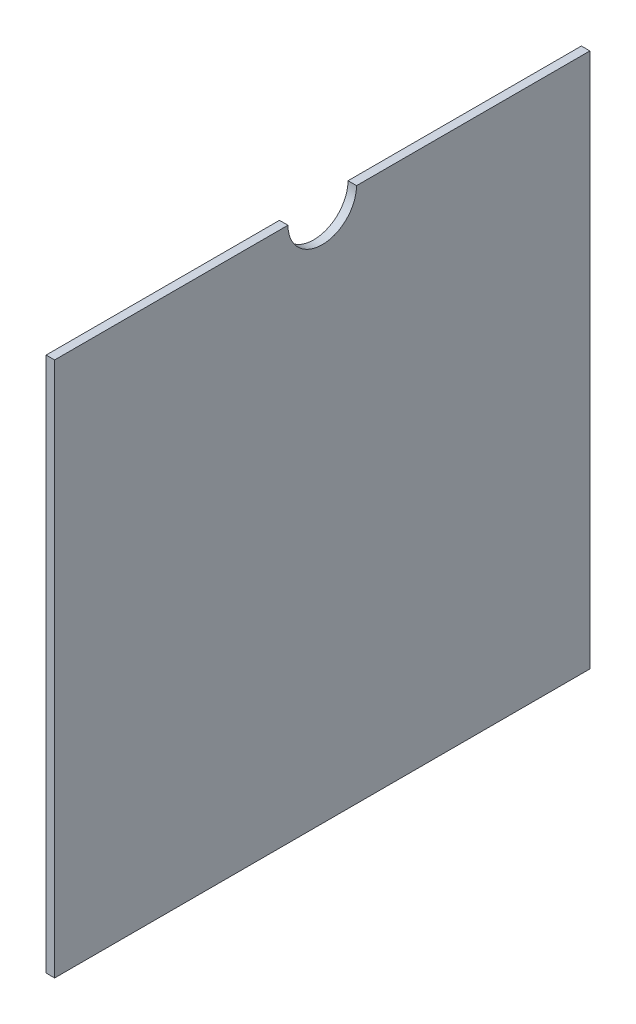
from build123d import *

# Parameters (mm, degrees)
BOSS_EXTRUDE1_DEPTH = 3.175
CUT_EXTRUDE1_DEPTH  = 3.175


with BuildPart() as part:
    # Sketch1 → Boss-Extrude1 (new body)
    with BuildSketch(Plane(origin=(0, 0, 0), x_dir=(0, 0, -1), z_dir=(1, 0, 0))):
        with BuildLine():
            Line((0, 199.9996), (87.2998, 199.9996))
            ThreePointArc((87.2998, 199.9996), (99.9998, 187.2996), (112.6998, 199.9996))
            Line((112.6998, 199.9996), (199.9996, 199.9996))
            Line((199.9996, 199.9996), (199.9996, 0))
            Line((199.9996, 0), (0, 0))
            Line((0, 0), (0, 199.9996))
        make_face()
    extrude(amount=BOSS_EXTRUDE1_DEPTH)

    # Sketch2 → Cut-Extrude1 (cut)
    with BuildSketch(Plane(origin=(3.175, 0, 0), x_dir=(0, 0, -1), z_dir=(1, 0, 0))):
        with BuildLine():
            Line((199.9996, 199.9996), (112.6998, 199.9996))
            ThreePointArc((112.6998, 199.9996), (99.9998, 187.2996), (87.2998, 199.9996))
            Line((87.2998, 199.9996), (0, 199.9996))
            Line((0, 199.9996), (0, 0))
            Line((0, 0), (199.9996, 0))
            Line((199.9996, 0), (199.9996, 199.9996))
        make_face()
        with BuildLine():
            Line((199.898, 199.898), (112.800996819, 199.898))
            ThreePointArc((112.800996819, 199.898), (99.9998, 187.198), (87.198603181, 199.898))
            Line((87.198603181, 199.898), (0.1016, 199.898))
            Line((0.1016, 199.898), (0.1016, 0.1016))
            Line((0.1016, 0.1016), (199.898, 0.1016))
            Line((199.898, 0.1016), (199.898, 199.898))
        make_face(mode=Mode.SUBTRACT)
    extrude(amount=-CUT_EXTRUDE1_DEPTH, mode=Mode.SUBTRACT)


solid = part.part
